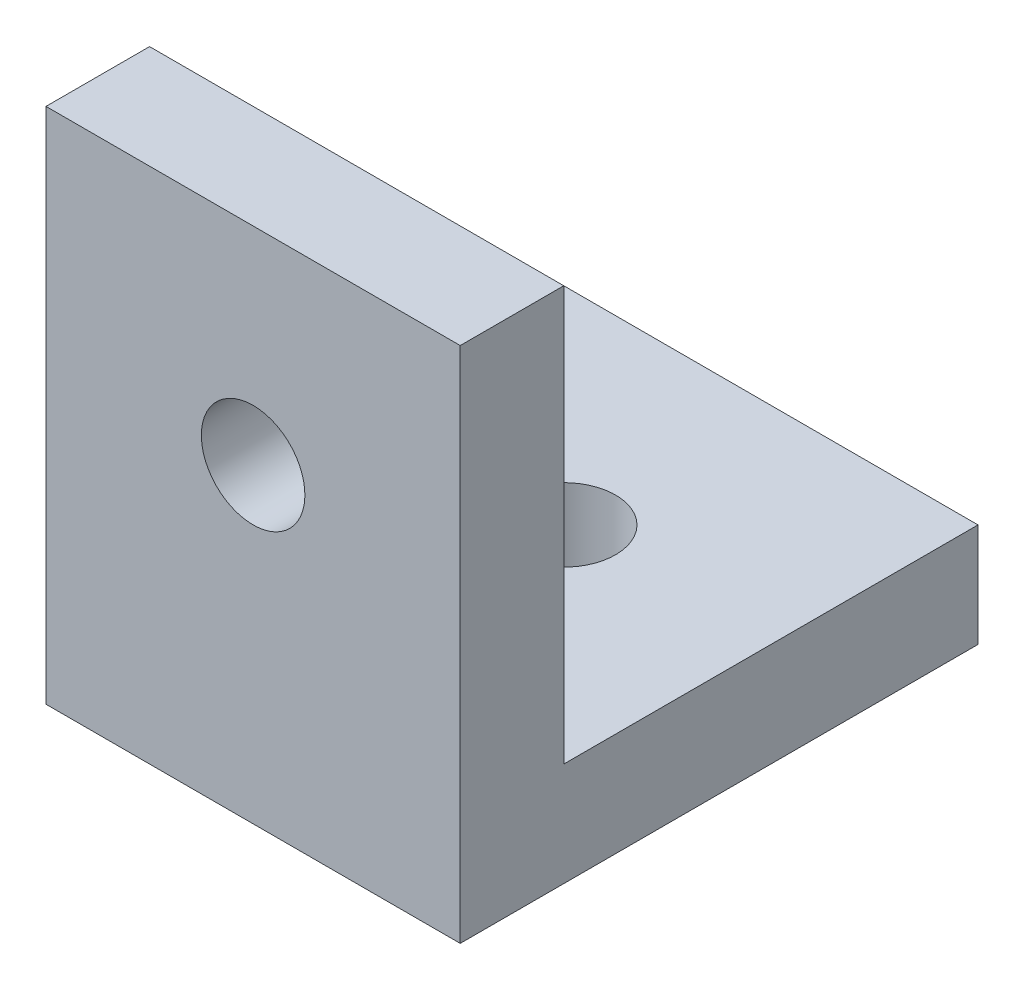
from build123d import *

# Parameters (mm, degrees)
BOSS_EXTRUDE1_DEPTH = 20
SKETCH2_R           = 2.5
CUT_EXTRUDE1_DEPTH  = 6
SKETCH3_R           = 2.5
CUT_EXTRUDE2_DEPTH  = 6


with BuildPart() as part:
    # Sketch1 → Boss-Extrude1 (new body)
    with BuildSketch(Plane(origin=(0, 0, 0), x_dir=(0, 0, -1), z_dir=(1, 0, 0))):
        Polygon((0, 0), (0, 25), (5, 25), (5, 5), (25, 5), (25, 0), align=None)
    extrude(amount=BOSS_EXTRUDE1_DEPTH)

    # Sketch2 → Cut-Extrude1 (cut, through all)
    with BuildSketch(Plane(origin=(0, 5, 0), x_dir=(1, 0, 0), z_dir=(0, 1, 0))):
        with Locations((10, 15)):
            Circle(SKETCH2_R)
    extrude(amount=-CUT_EXTRUDE1_DEPTH, mode=Mode.SUBTRACT)

    # Sketch3 → Cut-Extrude2 (cut, through all)
    with BuildSketch(Plane(origin=(0, 0, -5), x_dir=(-1, 0, 0), z_dir=(0, 0, -1))):
        with Locations((-10, 15)):
            Circle(SKETCH3_R)
    extrude(amount=-CUT_EXTRUDE2_DEPTH, mode=Mode.SUBTRACT)


solid = part.part
